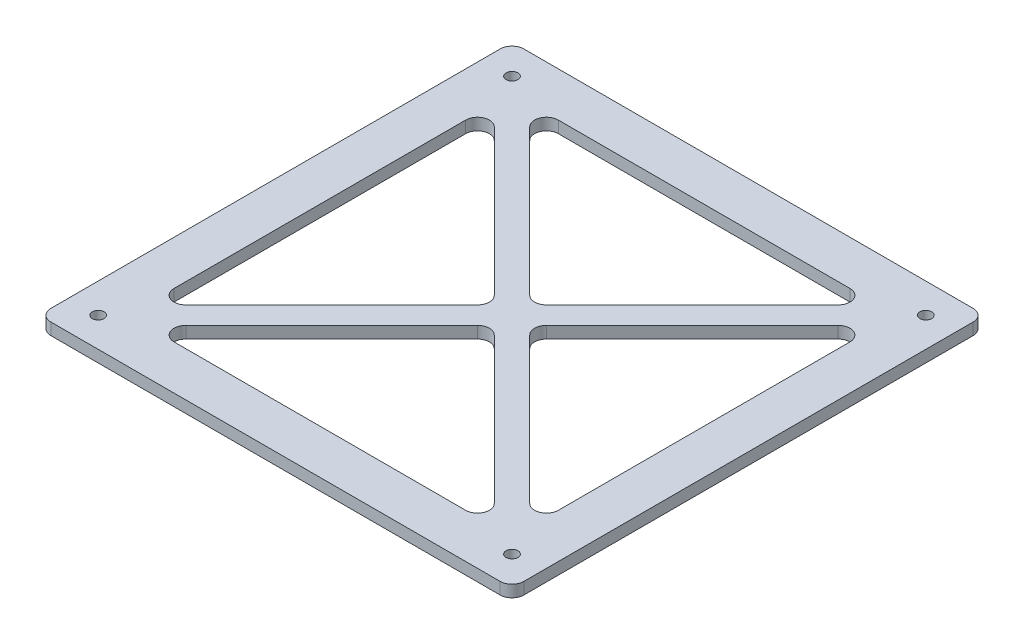
from build123d import *

# Parameters (mm, degrees)
SKETCH_1_R      = 1.5
EXTRUDE_1_DEPTH = 3


with BuildPart() as part:
    # 草圖1 → 填料-伸長1 (new body)
    with BuildSketch(Plane(origin=(0, 3, 0), x_dir=(1, 0, 0), z_dir=(0, 1, 0))):
        with BuildLine():
            Line((-60, 57), (-60, -57))
            ThreePointArc((-60, -57), (-59.121320344, -59.121320344), (-57, -60))
            Line((-57, -60), (57, -60))
            ThreePointArc((57, -60), (59.121320344, -59.121320344), (60, -57))
            Line((60, -57), (60, 57))
            ThreePointArc((60, 57), (59.121320344, 59.121320344), (57, 60))
            Line((57, 60), (-57, 60))
            ThreePointArc((-57, 60), (-59.121320344, 59.121320344), (-60, 57))
        make_face()
        with Locations((52.5, -52.5)):
            Circle(SKETCH_1_R, mode=Mode.SUBTRACT)
        with Locations((-52.5, 52.5)):
            Circle(SKETCH_1_R, mode=Mode.SUBTRACT)
        with Locations((52.5, 52.5)):
            Circle(SKETCH_1_R, mode=Mode.SUBTRACT)
        with Locations((-52.5, -52.5)):
            Circle(SKETCH_1_R, mode=Mode.SUBTRACT)
        with BuildLine():
            Line((43.628679656, -39.128679656), (6.621320344, -2.121320344))
            ThreePointArc((6.621320344, -2.121320344), (5.742640687, 0), (6.621320344, 2.121320344))
            Line((6.621320344, 2.121320344), (43.628679656, 39.128679656))
            ThreePointArc((43.628679656, 39.128679656), (46.898050297, 39.77899791), (48.75, 37.007359313))
            Line((48.75, 37.007359313), (48.75, -37.007359313))
            ThreePointArc((48.75, -37.007359313), (46.898050297, -39.77899791), (43.628679656, -39.128679656))
        make_face(mode=Mode.SUBTRACT)
        with BuildLine():
            Line((39.128679656, 43.628679656), (2.121320344, 6.621320344))
            ThreePointArc((2.121320344, 6.621320344), (0, 5.742640687), (-2.121320344, 6.621320344))
            Line((-2.121320344, 6.621320344), (-39.128679656, 43.628679656))
            ThreePointArc((-39.128679656, 43.628679656), (-39.77899791, 46.898050297), (-37.007359313, 48.75))
            Line((-37.007359313, 48.75), (37.007359313, 48.75))
            ThreePointArc((37.007359313, 48.75), (39.77899791, 46.898050297), (39.128679656, 43.628679656))
        make_face(mode=Mode.SUBTRACT)
        with BuildLine():
            Line((-39.128679656, -43.628679656), (-2.121320344, -6.621320344))
            ThreePointArc((-2.121320344, -6.621320344), (0, -5.742640687), (2.121320344, -6.621320344))
            Line((2.121320344, -6.621320344), (39.128679656, -43.628679656))
            ThreePointArc((39.128679656, -43.628679656), (39.77899791, -46.898050297), (37.007359313, -48.75))
            Line((37.007359313, -48.75), (-37.007359313, -48.75))
            ThreePointArc((-37.007359313, -48.75), (-39.77899791, -46.898050297), (-39.128679656, -43.628679656))
        make_face(mode=Mode.SUBTRACT)
        with BuildLine():
            Line((-48.75, -37.007359313), (-48.75, 37.007359313))
            ThreePointArc((-48.75, 37.007359313), (-46.898050297, 39.77899791), (-43.628679656, 39.128679656))
            Line((-43.628679656, 39.128679656), (-6.621320344, 2.121320344))
            ThreePointArc((-6.621320344, 2.121320344), (-5.742640687, 0), (-6.621320344, -2.121320344))
            Line((-6.621320344, -2.121320344), (-43.628679656, -39.128679656))
            ThreePointArc((-43.628679656, -39.128679656), (-46.898050297, -39.77899791), (-48.75, -37.007359313))
        make_face(mode=Mode.SUBTRACT)
    extrude(amount=-EXTRUDE_1_DEPTH)


solid = part.part
